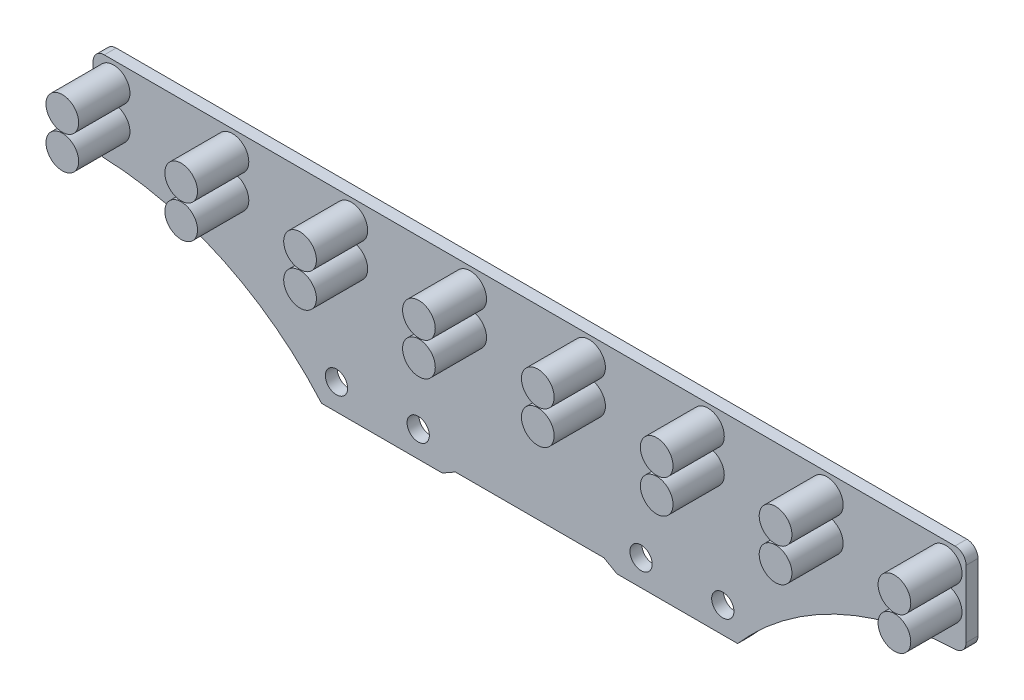
from build123d import *

# Parameters (mm, degrees)
SKETCH_1_W          = 117.5
SKETCH_1_H          = 26
EXTRUDE_1_DEPTH     = 1.6
SKETCH_2_R          = 2.2
EXTRUDE_4_DEPTH     = 6.9
SKETCH_3_R          = 1.5
CUT_EXTRUDE_2_DEPTH = 1.6
CUT_EXTRUDE_3_DEPTH = 1.6
SKETCH_5_W          = 20
SKETCH_5_H          = 9
EXTRUDE_5_DEPTH     = 9
SKETCH_6_W          = 18
SKETCH_6_H          = 7
CUT_EXTRUDE_4_DEPTH = 9
FILLET_1_R          = 1.5
CUT_EXTRUDE_5_DEPTH = 1.6
FILLET_2_R          = 1.5


with BuildPart() as part:
    # 草图1 → 凸台-拉伸1 (new body)
    with BuildSketch(Plane.XY):
        Rectangle(SKETCH_1_W, SKETCH_1_H)
    extrude(amount=EXTRUDE_1_DEPTH)

    # 草图2 → 凸台-拉伸4 (add)
    with BuildSketch(Plane.XY.offset(1.6)):
        with Locations((8, 10.25)):
            Circle(SKETCH_2_R)
        with Locations((8, 5.75)):
            Circle(SKETCH_2_R)
        with Locations((24, 10.25)):
            Circle(SKETCH_2_R)
        with Locations((24, 5.75)):
            Circle(SKETCH_2_R)
        with Locations((40, 10.25)):
            Circle(SKETCH_2_R)
        with Locations((40, 5.75)):
            Circle(SKETCH_2_R)
        with Locations((56, 10.25)):
            Circle(SKETCH_2_R)
        with Locations((56, 5.75)):
            Circle(SKETCH_2_R)
        with Locations((-8, 5.75)):
            Circle(SKETCH_2_R)
        with Locations((-8, 10.25)):
            Circle(SKETCH_2_R)
        with Locations((-24, 5.75)):
            Circle(SKETCH_2_R)
        with Locations((-24, 10.25)):
            Circle(SKETCH_2_R)
        with Locations((-40, 5.75)):
            Circle(SKETCH_2_R)
        with Locations((-40, 10.25)):
            Circle(SKETCH_2_R)
        with Locations((-56, 5.75)):
            Circle(SKETCH_2_R)
        with Locations((-56, 10.25)):
            Circle(SKETCH_2_R)
    extrude(amount=EXTRUDE_4_DEPTH)

    # 草图3 → 切除-拉伸2 (cut)
    with BuildSketch(Plane.XY.offset(1.6)):
        with Locations((-15, -9.5)):
            Circle(SKETCH_3_R)
        with Locations((15, -9.5)):
            Circle(SKETCH_3_R)
        with Locations((26, -9.5)):
            Circle(SKETCH_3_R)
        with Locations((-26, -9.5)):
            Circle(SKETCH_3_R)
    extrude(amount=-CUT_EXTRUDE_2_DEPTH, mode=Mode.SUBTRACT)

    # 草图4 → 切除-拉伸3 (cut)
    with BuildSketch(Plane(origin=(0, 0, 0), x_dir=(-1, 0, 0), z_dir=(0, 0, -1))):
        Polygon((-10, -12), (10, -12), (11.75, -13), (0, -13), (-11.75, -13), align=None)
    extrude(amount=-CUT_EXTRUDE_3_DEPTH, mode=Mode.SUBTRACT)

    # 草图5 → 凸台-拉伸5 (add)
    with BuildSketch(Plane(origin=(0, 0, 0), x_dir=(-1, 0, 0), z_dir=(0, 0, -1))):
        with Locations((0, -7.5)):
            Rectangle(SKETCH_5_W, SKETCH_5_H)
    extrude(amount=EXTRUDE_5_DEPTH)

    # 草图6 → 切除-拉伸4 (cut)
    with BuildSketch(Plane(origin=(0, 0, -9), x_dir=(-1, 0, 0), z_dir=(0, 0, -1))):
        with Locations((0, -7.5)):
            Rectangle(SKETCH_6_W, SKETCH_6_H)
    extrude(amount=-CUT_EXTRUDE_4_DEPTH, mode=Mode.SUBTRACT)

    # 圆角1
    fillet_1_edges = [part.edges().sort_by_distance(p)[0] for p in [
        (-58.75, 13, 0.8),
        (58.75, 13, 0.8),
    ]]
    fillet(fillet_1_edges, radius=FILLET_1_R)

    # 草图7 → 切除-拉伸5 (cut)
    with BuildSketch(Plane(origin=(0, 0, 0), x_dir=(-1, 0, 0), z_dir=(0, 0, -1))):
        with BuildLine():
            Line((28, -13), (58.75, -13))
            Line((58.75, -13), (58.75, 1))
            ThreePointArc((58.75, 1), (41.856491631, -2.664704833), (28, -13))
        make_face()
        with BuildLine():
            Line((-58.75, 1), (-58.75, -13))
            Line((-58.75, -13), (-28, -13))
            ThreePointArc((-28, -13), (-41.856491631, -2.664704833), (-58.75, 1))
        make_face()
    extrude(amount=-CUT_EXTRUDE_5_DEPTH, mode=Mode.SUBTRACT)

    # 圆角2
    fillet_2_edges = [part.edges().sort_by_distance(p)[0] for p in [
        (-58.75, 1, 0.8),
        (58.75, 1, 0.8),
    ]]
    fillet(fillet_2_edges, radius=FILLET_2_R)


solid = part.part
